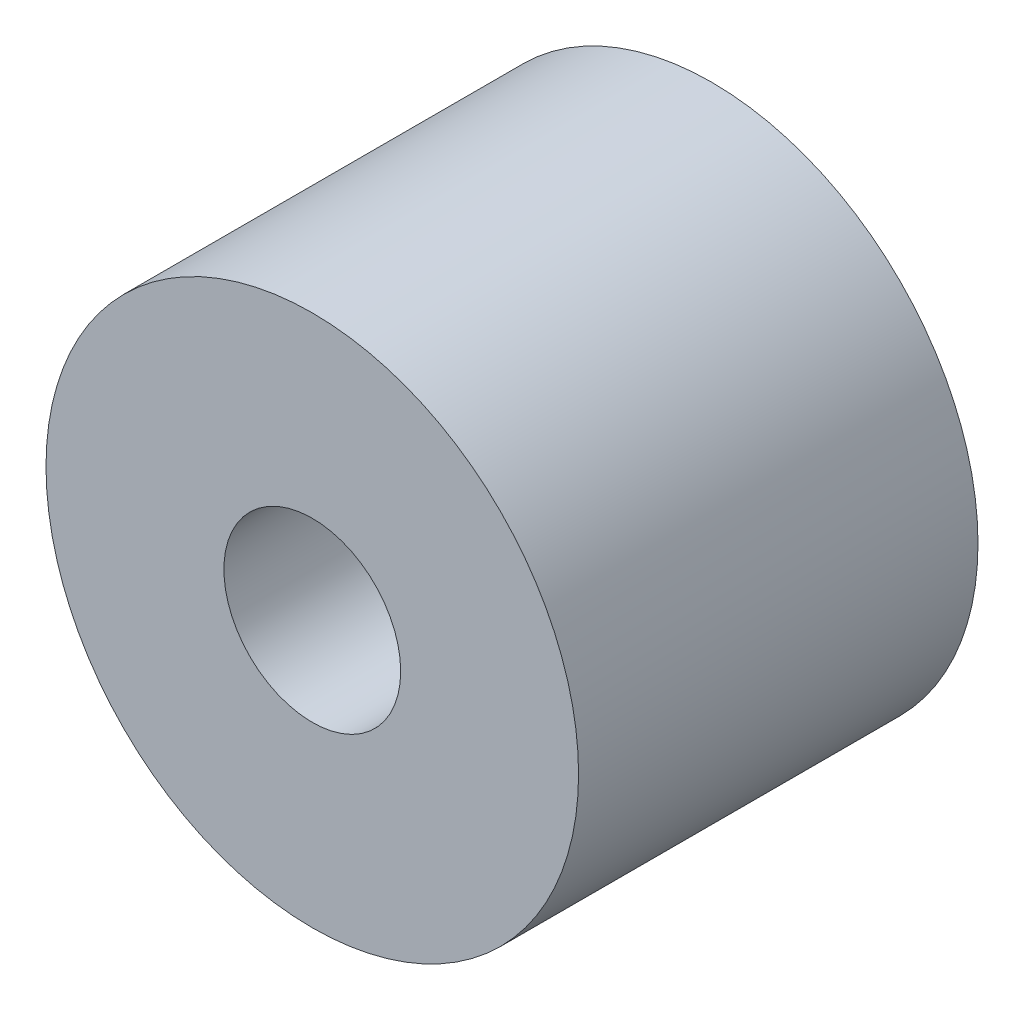
from build123d import *

# Parameters (mm, degrees)
SKETCH1_R      = 6.35
SKETCH1_R_2    = 2.1082
EXTRUDE1_DEPTH = 4.7625


with BuildPart() as part:
    # Sketch1 → Extrude1 (new body, symmetric)
    with BuildSketch(Plane.XY):
        Circle(SKETCH1_R)
        Circle(SKETCH1_R_2, mode=Mode.SUBTRACT)
    extrude(amount=EXTRUDE1_DEPTH, both=True)


solid = part.part
